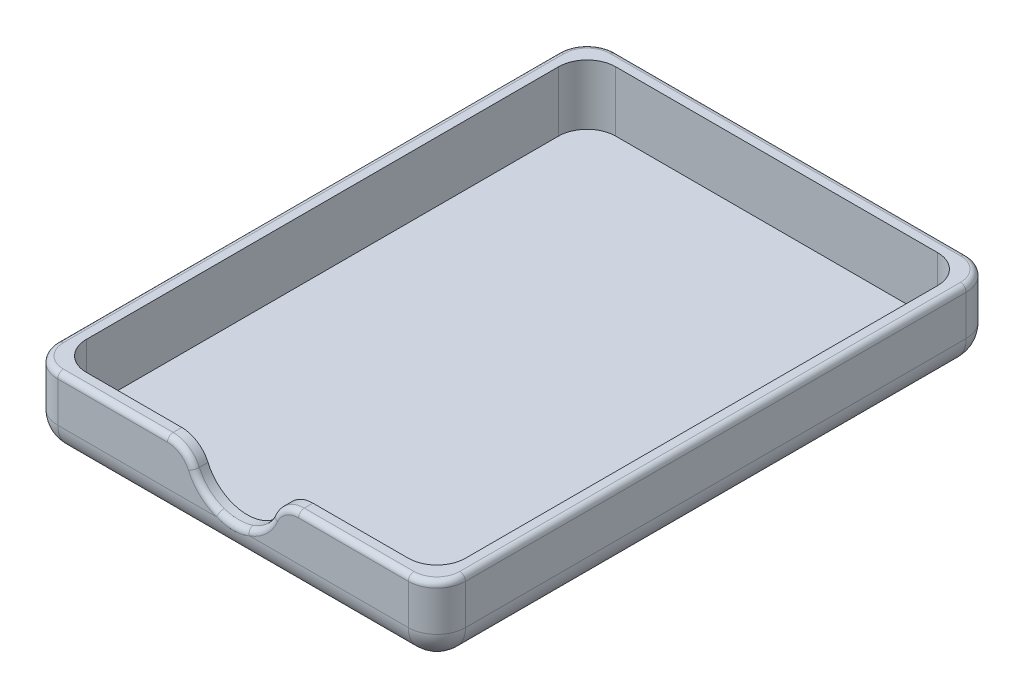
from build123d import *

# Parameters (mm, degrees)
BOSS_EXTRUDE1_DEPTH = 5
BOSS_EXTRUDE2_DEPTH = 185
BOSS_EXTRUDE3_DEPTH = 5
FILLET1_R           = 10
FILLET2_R           = 2


with BuildPart() as part:
    # Sketch1 → Boss-Extrude1 (new body)
    with BuildSketch(Plane.XY):
        with BuildLine():
            Line((-71.25, 13), (-71.25, -13))
            Line((-71.25, -13), (71.25, -13))
            Line((71.25, -13), (71.25, 13))
            Line((71.25, 13), (15, 13))
            ThreePointArc((15, 13), (0, -2), (-15, 13))
            Line((-15, 13), (-71.25, 13))
        make_face()
    extrude(amount=-BOSS_EXTRUDE1_DEPTH)

    # Sketch2 → Boss-Extrude2 (add)
    with BuildSketch(Plane(origin=(0, 0, -5), x_dir=(-1, 0, 0), z_dir=(0, 0, -1))):
        Polygon((-66.25, -8), (-66.25, 8), (-66.25, 13), (-71.25, 13), (-71.25, -13), (71.25, -13), (71.25, 13), (66.25, 13), (66.25, 8), (66.25, -8), align=None)
    extrude(amount=BOSS_EXTRUDE2_DEPTH)

    # Sketch3 → Boss-Extrude3 (add)
    with BuildSketch(Plane(origin=(0, 0, -190), x_dir=(-1, 0, 0), z_dir=(0, 0, -1))):
        with BuildLine():
            Line((-66.25, 13), (-66.25, -8))
            Line((-66.25, -8), (66.25, -8))
            Line((66.25, -8), (66.25, 13))
            Line((66.25, 13), (15, 13))
            ThreePointArc((15, 13), (0, -2), (-15, 13))
            Line((-15, 13), (-66.25, 13))
        make_face()
        with BuildLine():
            Line((15, 13), (-15, 13))
            ThreePointArc((-15, 13), (0, -2), (15, 13))
        make_face()
        Polygon((71.25, 13), (66.25, 13), (66.25, -8), (-66.25, -8), (-66.25, 13), (-71.25, 13), (-71.25, -13), (71.25, -13), align=None)
    extrude(amount=BOSS_EXTRUDE3_DEPTH)

    # Fillet1
    fillet1_edges = [part.edges().sort_by_distance(p)[0] for p in [
        (71.25, -13, -97.5),
        (-71.25, -13, -97.5),
        (-15, 13, -2.5),
        (15, 13, -2.5),
        (-66.25, 2.5, -190),
        (66.25, 2.5, -190),
        (-66.25, 2.5, -5),
        (66.25, 2.5, -5),
        (71.25, 0, -195),
        (0, -13, -195),
        (-71.25, 0, -195),
        (71.25, 0, 0),
        (0, -13, 0),
        (-71.25, 0, 0),
    ]]
    fillet(fillet1_edges, radius=FILLET1_R)

    # Fillet2
    fillet2_edges = [part.edges().sort_by_distance(p)[0] for p in [
        (68.321067812, 13, -192.071067812),
        (-68.321067812, 13, -192.071067812),
        (42.081439237, 13, 0),
        (0, -2, 0),
        (-42.081439237, 13, 0),
        (-17.4356529, 11.366600265, 0),
        (17.4356529, 11.366600265, 0),
        (0, 13, -195),
        (71.25, 13, -97.5),
        (-71.25, 13, -97.5),
        (-68.321067812, 13, -2.928932188),
        (68.321067812, 13, -2.928932188),
    ]]
    fillet(fillet2_edges, radius=FILLET2_R)


solid = part.part
